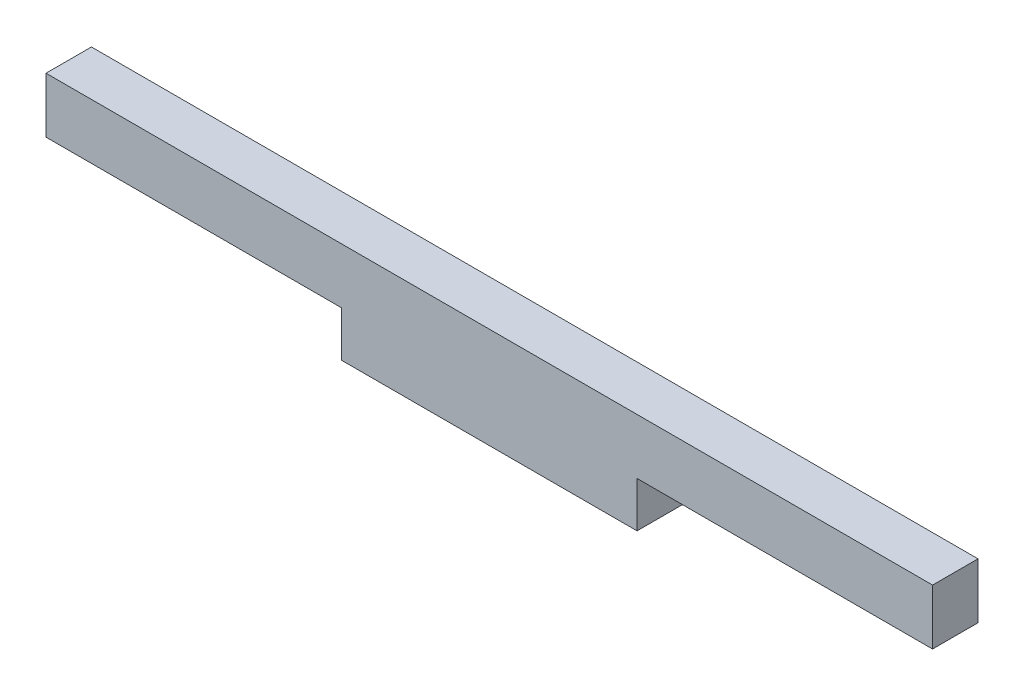
from build123d import *

# Parameters (mm, degrees)
BOSS_EXTRUDE1_DEPTH = 5.207


with BuildPart() as part:
    # Sketch1 → Boss-Extrude1 (new body)
    with BuildSketch(Plane.XY):
        Polygon((67.733333333, 0), (101.6, 0), (101.6, 6.35), (0, 6.35), (0, 0), (33.866666667, 0), (33.866666667, -5.207), (67.733333333, -5.207), align=None)
    extrude(amount=BOSS_EXTRUDE1_DEPTH)


solid = part.part
